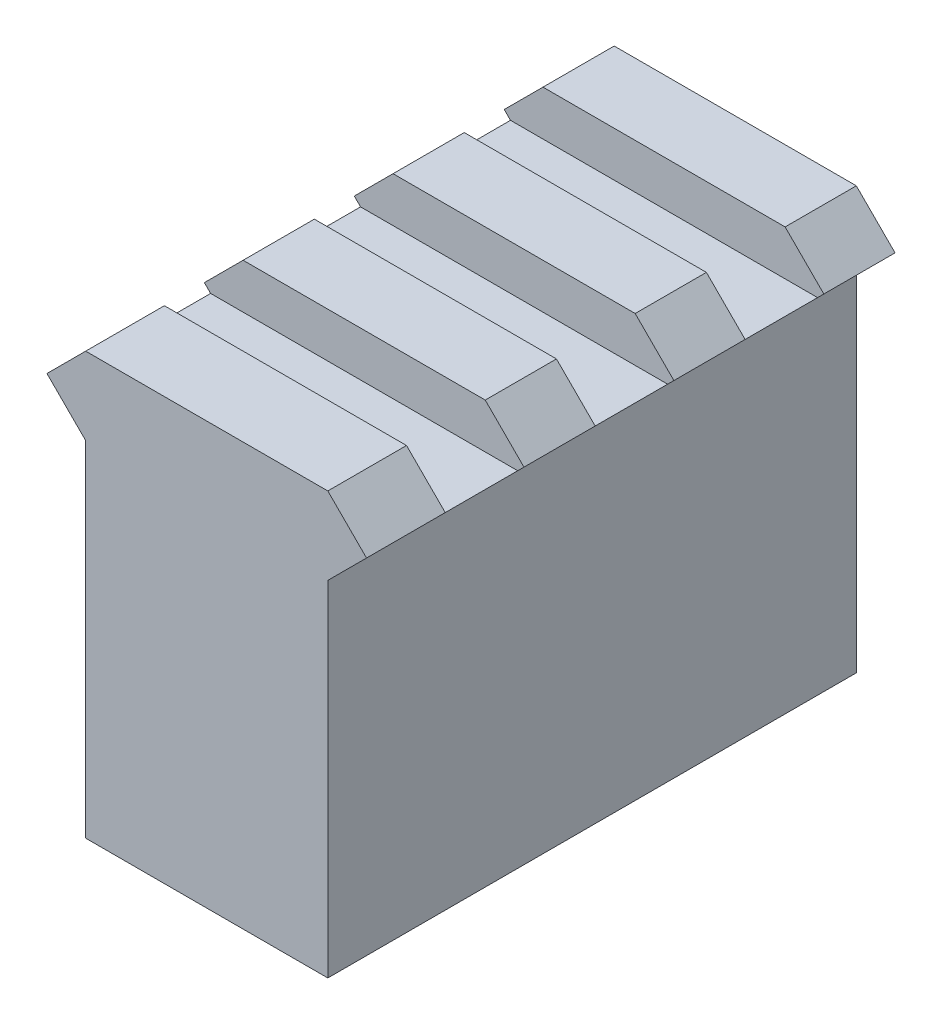
from build123d import *

# Parameters (mm, degrees)
BOSS_EXTRUDE1_DEPTH         = 35.25
F_1_4_20_TAPPED_HOLE1_D     = 5.1054
F_1_4_20_TAPPED_HOLE1_DEPTH = 15
F_1_4_20_TAPPED_HOLE1_TIP   = 1.533816902
SKETCH4_W                   = 6.24022781
SKETCH4_H                   = 5.25
SKETCH4_W_2                 = 16.14963906
SKETCH4_W_3                 = 28.63009468
CUT_EXTRUDE1_DEPTH          = 3


with BuildPart() as part:
    # Sketch1 → Boss-Extrude1 (new body)
    with BuildSketch(Plane.XY):
        Polygon((-8.07481953, 0), (8.07481953, 0), (8.07481953, 22.9672), (10.65761953, 25.55), (8.07481953, 28.1328), (-8.07481953, 28.1328), (-10.65761953, 25.55), (-8.07481953, 22.9672), align=None)
    extrude(amount=BOSS_EXTRUDE1_DEPTH)

    # 1/4-20 Tapped Hole1
    with Locations(Plane(origin=(0, 0, 0), x_dir=(-1, 0, 0), z_dir=(0, -1, 0))):
        with Locations((0, -8.25), (0, -28.25)):
            Hole(F_1_4_20_TAPPED_HOLE1_D / 2, depth=F_1_4_20_TAPPED_HOLE1_DEPTH)
            with Locations((0, 0, -(F_1_4_20_TAPPED_HOLE1_DEPTH + F_1_4_20_TAPPED_HOLE1_TIP / 2))):  # 118° drill point
                Cone(0, F_1_4_20_TAPPED_HOLE1_D / 2, F_1_4_20_TAPPED_HOLE1_TIP, mode=Mode.SUBTRACT)

    # Sketch4 → Cut-Extrude1 (cut)
    with BuildSketch(Plane(origin=(0, 28.1328, 0), x_dir=(1, 0, 0), z_dir=(0, 1, 0))):
        with Locations((-11.194933435, -17.375)):
            Rectangle(SKETCH4_W, SKETCH4_H)
        with Locations((0, -17.375)):
            Rectangle(SKETCH4_W_2, SKETCH4_H)
        with Locations((11.194933435, -17.375)):
            Rectangle(SKETCH4_W, SKETCH4_H)
        with Locations((-11.194933435, -27.375)):
            Rectangle(SKETCH4_W, SKETCH4_H)
        with Locations((0, -27.375)):
            Rectangle(SKETCH4_W_2, SKETCH4_H)
        with Locations((11.194933435, -27.375)):
            Rectangle(SKETCH4_W, SKETCH4_H)
        with Locations((0, -7.375)):
            Rectangle(SKETCH4_W_3, SKETCH4_H)
    extrude(amount=-CUT_EXTRUDE1_DEPTH, mode=Mode.SUBTRACT)


solid = part.part
